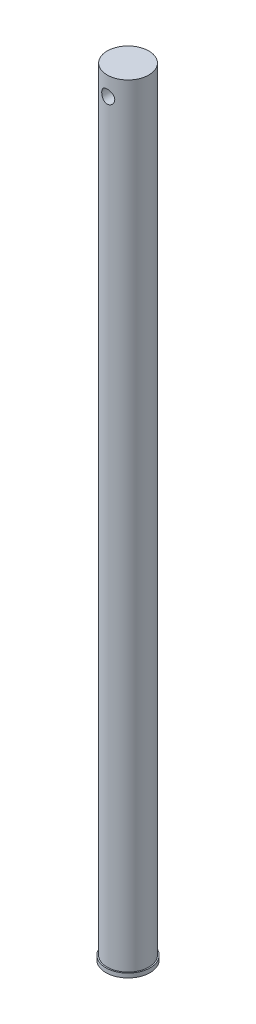
from build123d import *

# Parameters (mm, degrees)
CROQUIS1_R              = 9.906
SALIENTE_EXTRUIR1_DEPTH = 367.538
CROQUIS2_R              = 3.1
CORTAR_EXTRUIR1_DEPTH   = 10
CROQUIS3_R              = 10.5
SALIENTE_EXTRUIR2_DEPTH = 2


with BuildPart() as part:
    # Croquis1 → Saliente-Extruir1 (new body)
    with BuildSketch(Plane(origin=(0, 0, 0), x_dir=(1, 0, 0), z_dir=(0, 1, 0))):
        Circle(CROQUIS1_R)
    extrude(amount=SALIENTE_EXTRUIR1_DEPTH)

    # Croquis2 → Cortar-Extruir1 (cut, symmetric)
    with BuildSketch(Plane.XY):
        with Locations((0, 358.648)):
            Circle(CROQUIS2_R)
    extrude(amount=CORTAR_EXTRUIR1_DEPTH, both=True, mode=Mode.SUBTRACT)

    # Croquis3 → Saliente-Extruir2 (add)
    with BuildSketch(Plane.XZ):
        Circle(CROQUIS3_R)
    extrude(amount=SALIENTE_EXTRUIR2_DEPTH)


solid = part.part
